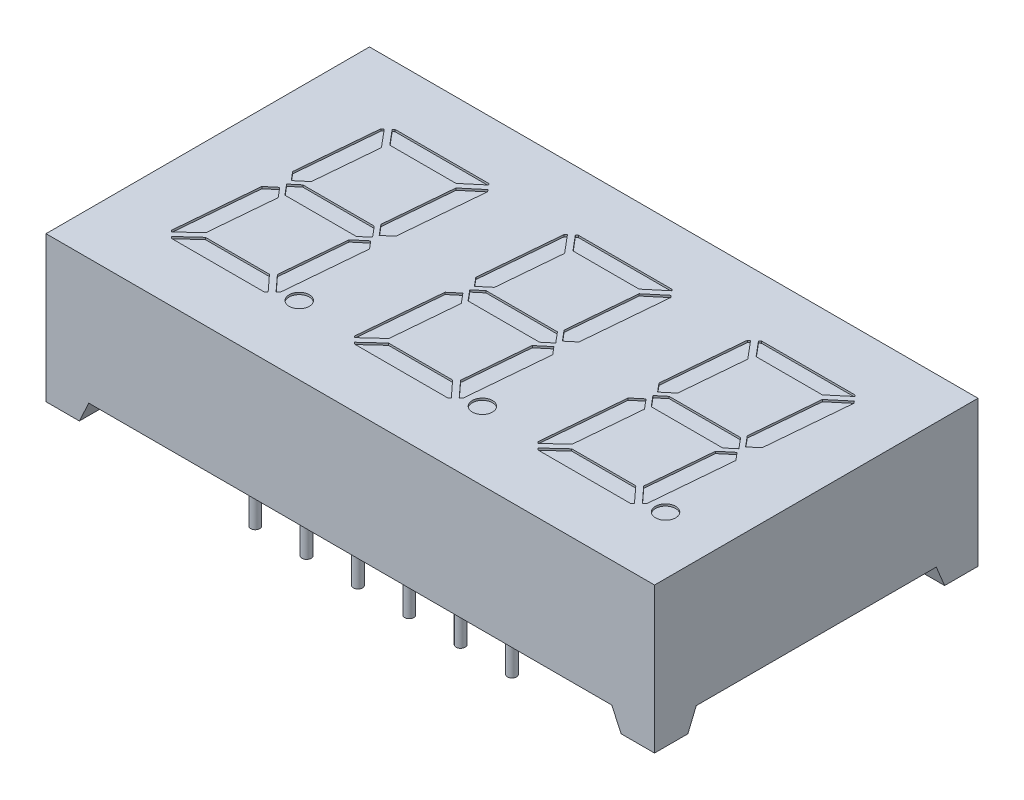
from build123d import *

# Parameters (mm, degrees)
SKETCH1_W                       = 30.1
SKETCH1_H                       = 16
EXTRUDE1_DEPTH                  = 7.2
SKETCH6_R                       = 0.498915
CUT_EXTRUDE1_DEPTH              = 0.1
CUT_EXTRUDE2_DEPTH              = 32.966388598
CUT_EXTRUDE2_DEPTH_BACK         = 32.966388598
CUT_EXTRUDE3_DEPTH              = 24.115849541
CUT_EXTRUDE3_DEPTH_BACK         = 24.115849541
LPATTERN1_COUNT                 = 2
LPATTERN1_PITCH                 = 9.06
LPATTERN2_COUNT                 = 2
LPATTERN2_PITCH                 = 9.06
SKETCH11_R                      = 0.225
BOSS_EXTRUDE4_DEPTH             = 1.8
BOSS_EXTRUDE4_DIRECTION_2_REACH = 20.502
LPATTERN3_COUNT                 = 6
LPATTERN3_PITCH                 = 2.54
LPATTERN3_COUNT_DIR2            = 2
LPATTERN3_PITCH_DIR2            = 12.7


with BuildPart() as part:
    # Sketch1 → Extrude1 (new body)
    with BuildSketch(Plane(origin=(0, 0, 0), x_dir=(1, 0, 0), z_dir=(0, 1, 0))):
        Rectangle(SKETCH1_W, SKETCH1_H)
    extrude(amount=-EXTRUDE1_DEPTH)

    # Sketch6 → Cut-Extrude1 (cut)
    with BuildSketch(Plane(origin=(0, 0, 0), x_dir=(-1, 0, 0), z_dir=(0, 1, 0))):
        with Locations((-3.136417605, 4.601105)):
            Circle(SKETCH6_R)
        Polygon((1.899392179, -5.031807345), (1.818099503, -5.10002), (-2.815721224, -5.10002), (-2.872958438, -5.031807345), (-1.993362607, -4.293738808), (1.280079142, -4.293738808), align=None)
        Polygon((-2.771014452, -0.541251787), (-3.136417605, -4.717828937), (-3.051123094, -4.819478977), (-2.191884627, -4.098492296), (-1.893012763, -0.682371264), (-2.325269688, -0.16722752), align=None)
        Polygon((1.729773181, 0.44348), (-1.804005322, 0.44348), (-2.240747865, 0.077009494), (-1.804005322, -0.44348), (1.729773181, -0.44348), (2.166515723, -0.077009494), align=None)
        Polygon((1.379758426, -3.981324201), (1.658740499, -0.792544509), (2.198389312, -0.33972539), (2.551851384, -0.760965084), (2.200290566, -4.77932362), (2.111720548, -4.85364269), align=None)
        Polygon((-1.276746018, 4.21306), (-2.008340937, 5.011455754), (-1.919776691, 5.10002), (2.680970165, 5.10002), (2.766330848, 5.014659317), (1.8915387, 4.21306), align=None)
        Polygon((-1.481100864, 4.025803284), (-2.204519978, 4.815276713), (-2.311761335, 4.708035356), (-2.66642341, 0.654229291), (-2.348850987, 0.275761216), (-1.766430556, 0.764469985), align=None)
        Polygon((2.078795416, 4.008705154), (2.962509889, 4.818480275), (3.033756345, 4.74723382), (2.674290947, 0.638525521), (2.193846693, 0.235384926), (1.790706097, 0.715829179), align=None)
    cut_extrude1 = extrude(amount=-CUT_EXTRUDE1_DEPTH, mode=Mode.SUBTRACT)

    # Sketch12 → Cut-Extrude2 (cut, two sides: drawn at the far end of the back side and taken through both)
    with BuildSketch(Plane.ZY.offset(15.05).offset(-CUT_EXTRUDE2_DEPTH_BACK)):
        Polygon((-22.464786823, -46.104536903), (-6.35, -7.2), (-5.935786438, -6.2), (5.935786438, -6.2), (6.35, -7.2), (22.464786823, -46.104536903), (22.464786823, -130.324471503), (-22.464786823, -130.324471503), align=None)
    extrude(amount=CUT_EXTRUDE2_DEPTH + CUT_EXTRUDE2_DEPTH_BACK, mode=Mode.SUBTRACT)

    # Sketch13 → Cut-Extrude3 (cut, two sides: drawn at the far end of the back side and taken through both)
    with BuildSketch(Plane(origin=(0, 0, -8), x_dir=(-1, 0, 0), z_dir=(0, 0, -1)).offset(-CUT_EXTRUDE3_DEPTH_BACK)):
        Polygon((-42.431282579, -69.457786403), (-13.4, -7.2), (-12.933692342, -6.2), (12.933692342, -6.2), (13.4, -7.2), (42.431282579, -69.457786403), (42.431282579, -206.845520004), (-42.431282579, -206.845520004), align=None)
    extrude(amount=CUT_EXTRUDE3_DEPTH + CUT_EXTRUDE3_DEPTH_BACK, mode=Mode.SUBTRACT)

    # LPattern1: Cut-Extrude1 ×2
    with Locations(*[(i * LPATTERN1_PITCH, 0, 0) for i in range(1, LPATTERN1_COUNT)]):
        add(cut_extrude1, mode=Mode.SUBTRACT)

    # LPattern2: Cut-Extrude1 ×2
    with Locations(*[(-i * LPATTERN2_PITCH, 0, 0) for i in range(1, LPATTERN2_COUNT)]):
        add(cut_extrude1, mode=Mode.SUBTRACT)

    # Sketch11 → Boss-Extrude4 (add)
    with BuildSketch(Plane.XZ.offset(7.2)):
        with Locations((6.35, 6.35)):
            Circle(SKETCH11_R)
    boss_extrude4 = extrude(amount=BOSS_EXTRUDE4_DEPTH)

    # Sketch11 → Boss-Extrude4 direction 2 (add, up to next)
    with BuildSketch(Plane.XZ.offset(7.2), mode=Mode.PRIVATE) as boss_extrude4_direction_2_sk1:
        with Locations((6.35, 6.35)):
            Circle(SKETCH11_R)
    boss_extrude4_direction_2_tool1 = extrude(boss_extrude4_direction_2_sk1.sketch, amount=-BOSS_EXTRUDE4_DIRECTION_2_REACH, mode=Mode.PRIVATE) - part.part
    boss_extrude4_direction_2 = boss_extrude4_direction_2_tool1.solids().sort_by_distance((6.35, -7.2, 6.35))[0]
    add(boss_extrude4_direction_2)

    # LPattern3: Boss-Extrude4, Boss-Extrude4 direction 2 6 × 2
    with Locations(*[(-i * LPATTERN3_PITCH, 0, -j * LPATTERN3_PITCH_DIR2) for i in range(LPATTERN3_COUNT) for j in range(LPATTERN3_COUNT_DIR2) if (i, j) != (0, 0)]):
        add(boss_extrude4)
        add(boss_extrude4_direction_2)


solid = part.part
